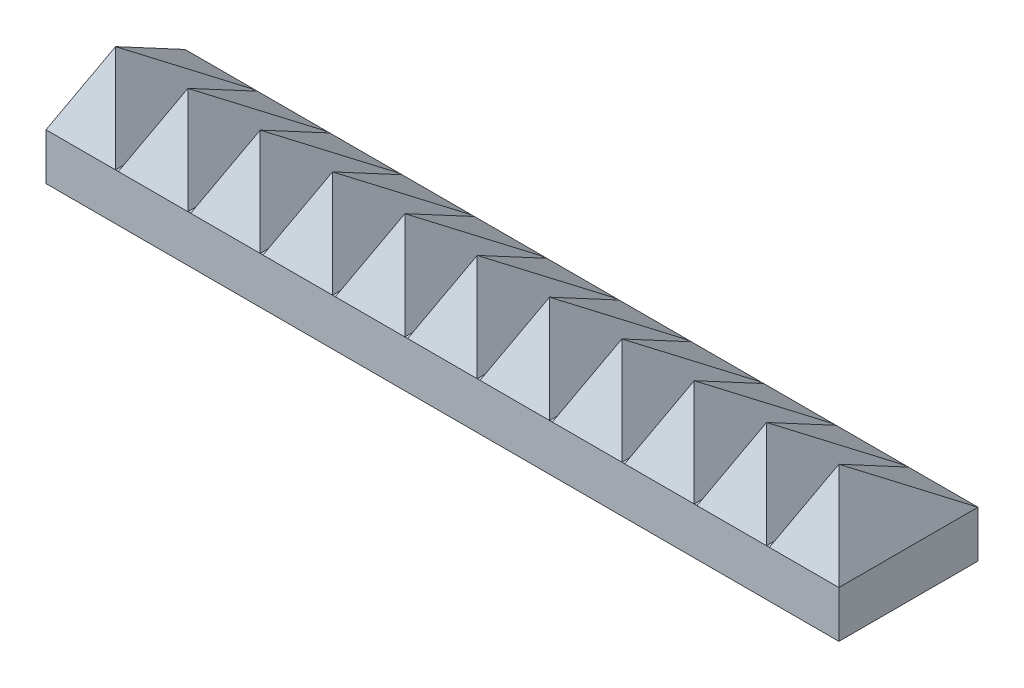
from build123d import *

# Parameters (mm, degrees)
SKETCH1_W           = 19.05
SKETCH1_H           = 19.05
BOSS_EXTRUDE2_DEPTH = 6.35
SKETCH8_W           = 217.17
SKETCH8_H           = 38.1
BOSS_EXTRUDE4_DEPTH = 6.35
SKETCH8_5_W         = 217.17
SKETCH8_5_H         = 38.1
BOSS_EXTRUDE5_DEPTH = 6.4262
LPATTERN3_COUNT     = 11
LPATTERN3_PITCH     = 19.812
SKETCH15_R          = 12.192
BOSS_EXTRUDE6_DEPTH = 6.35


with BuildPart() as part:
    # Sketch1 → Boss-Extrude2 (new body)
    with BuildSketch(Plane(origin=(0, 0, 0), x_dir=(1, 0, 0), z_dir=(0, 1, 0))):
        with Locations((9.525, -9.525)):
            Rectangle(SKETCH1_W, SKETCH1_H)
    extrude(amount=BOSS_EXTRUDE2_DEPTH)

    # Sketch8 → Boss-Extrude4 (add)
    with BuildSketch(Plane(origin=(0, 0, 0), x_dir=(1, 0, 0), z_dir=(0, 1, 0))):
        with Locations((108.585, -9.525)):
            Rectangle(SKETCH8_W, SKETCH8_H)
    extrude(amount=BOSS_EXTRUDE4_DEPTH)

    # Sketch8_5 → Boss-Extrude5 (add)
    with BuildSketch(Plane(origin=(0, 0, 0), x_dir=(1, 0, 0), z_dir=(0, 1, 0))):
        with Locations((108.585, -9.525)):
            Rectangle(SKETCH8_5_W, SKETCH8_5_H)
    extrude(amount=-BOSS_EXTRUDE5_DEPTH)

    # Sketch9 → Loft3 section 0
    with BuildSketch(Plane(origin=(0, 6.35, 0), x_dir=(1, 0, 0), z_dir=(0, 1, 0)), mode=Mode.PRIVATE) as loft3_s0:
        with BuildLine():
            Line((0, 9.525), (19.05, 9.525))
            Line((19.05, 9.525), (19.05, -28.575))
            Line((19.05, -28.575), (0, -28.575))
            Line((0, -28.575), (0, 9.525))
        make_face()
    loft3 = loft([loft3_s0.sketch, Vertex(9.525, 26.0731, 19.05)])

    # LPattern3: Loft3 ×11
    with Locations(*[(i * LPATTERN3_PITCH, 0, 0) for i in range(1, LPATTERN3_COUNT)]):
        add(loft3)

    # Sketch15 → Boss-Extrude6 (add)
    with BuildSketch(Plane.XZ.offset(6.4262)):
        with Locations((179.07, 9.525)):
            Circle(SKETCH15_R)
        with Locations((38.1, 9.525)):
            Circle(SKETCH15_R)
        with Locations((108.585, 9.525)):
            Circle(SKETCH15_R)
    extrude(amount=BOSS_EXTRUDE6_DEPTH)


solid = part.part
